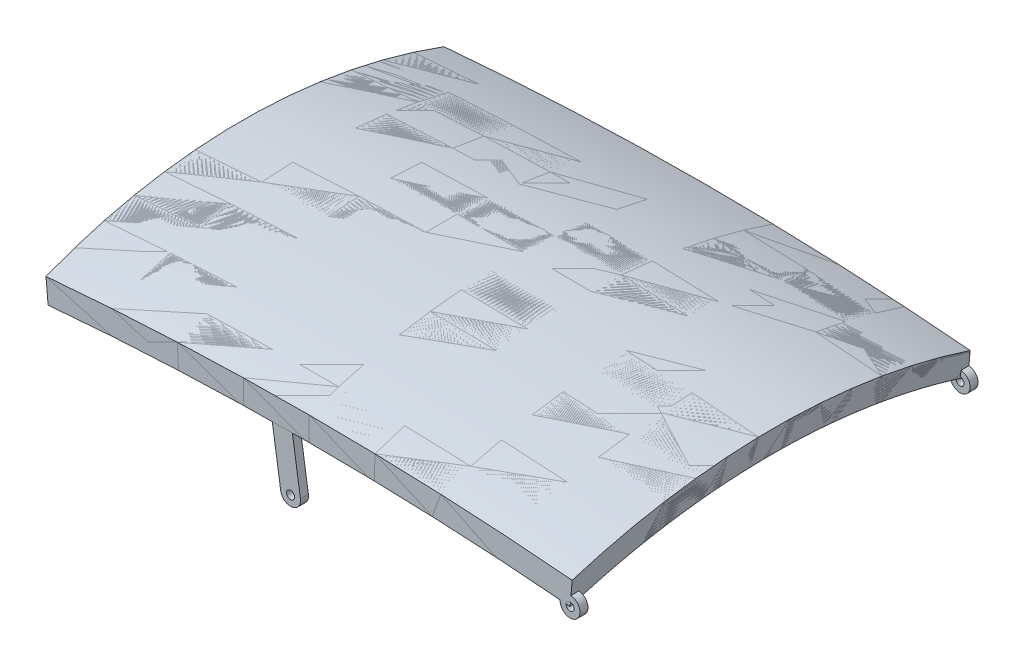
from build123d import *

# Parameters (mm, degrees)
SKETCH3_R           = 10
BOSS_EXTRUDE1_DEPTH = 20
SKETCH4_R           = 25
BOSS_EXTRUDE2_DEPTH = 20
SKETCH5_R           = 10
CUT_EXTRUDE1_DEPTH  = 40


with BuildPart() as part:
    # Sweep1: sweep along a path in Sketch1
    with BuildLine(Plane.XY) as sweep1_path:
        ThreePointArc((-381.346255507, 0), (274.453744493, 28.976752889), (930.253744493, 0))
    # Sketch2 → Sweep1 (sweep)
    with BuildSketch(Plane(origin=(-381.346255507, 0, 0), x_dir=(0, 0, -1), z_dir=(0.996102918, 0.088198507, 0))):
        with BuildLine():
            Line((1000, 0), (1000, 60))
            ThreePointArc((1000, 60), (500, 145.786437627), (0, 60))
            Line((0, 60), (0, 0))
            ThreePointArc((0, 0), (500, 85.786437627), (1000, 0))
        make_face()
    sweep(path=sweep1_path.line)

    # Sketch4 → Boss-Extrude2 (add)
    with BuildSketch(Plane.XY):
        with Locations((930.253744493, 0)):
            Circle(SKETCH4_R)
    extrude(amount=-BOSS_EXTRUDE2_DEPTH)

    # Sketch5 → Cut-Extrude1 (cut)
    with BuildSketch(Plane.XY):
        with Locations((930.253744493, 0)):
            Circle(SKETCH5_R)
    extrude(amount=-CUT_EXTRUDE1_DEPTH, mode=Mode.SUBTRACT)


with BuildPart() as body_2:
    # Sketch3 → Boss-Extrude1 (new body)
    with BuildSketch(Plane.XY):
        with BuildLine():
            Line((230.462804943, 41.688976459), (179.888879124, 41.688976459))
            Line((179.888879124, 41.688976459), (203.254594848, -112.083465063))
            ThreePointArc((203.254594848, -112.083465063), (231.726528195, -133.044118954), (252.687182085, -104.572185607))
            Line((252.687182085, -104.572185607), (230.462804943, 41.688976459))
        make_face()
        with Locations((227.970888467, -108.327825335)):
            Circle(SKETCH3_R, mode=Mode.SUBTRACT)
    extrude(amount=-BOSS_EXTRUDE1_DEPTH)


with BuildPart() as body_3:
    # Mirror5: mirrored copy
    add(body_2.part.mirror(Plane.XY.offset(-500)))


with BuildPart() as body_4:
    # Mirror5 2: mirrored copy
    add(part.part.mirror(Plane.XY.offset(-500)))


solid = Compound([part.part, body_2.part, body_3.part, body_4.part])
